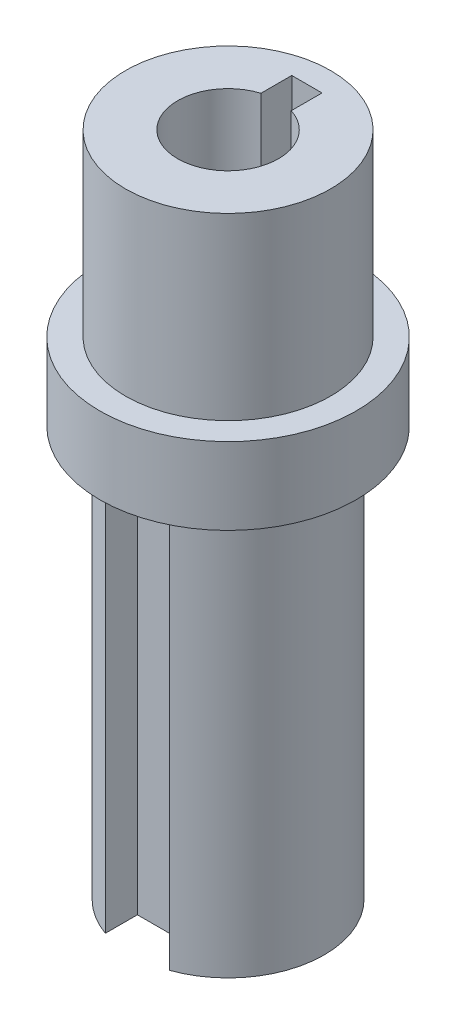
from build123d import *

# Parameters (mm, degrees)
CUT_EXTRUDE1_DEPTH = 21.8
CUT_EXTRUDE2_DEPTH = 39.37


with BuildPart() as part:
    # Sketch2 → Revolve1 (revolve)
    with BuildSketch(Plane.XY):
        Polygon((-10.16, 0), (-4.9911, 0), (-4.9911, -34.29), (-2.032, -34.29), (-2.032, -66.04), (-9.525, -66.04), (-9.525, -25.4), (-12.7, -25.4), (-12.7, -17.78), (-10.16, -17.78), align=None)
    revolve(axis=Axis((0, 0, 0), (0, -1, 0)))

    # Sketch4 → Cut-Extrude1 (cut)
    with BuildSketch(Plane(origin=(0, 0, 0), x_dir=(1, 0, 0), z_dir=(0, 1, 0))):
        with BuildLine():
            Line((1.5, 4.760365449), (1.5, 7.81))
            Line((1.5, 7.81), (-1.5, 7.81))
            Line((-1.5, 7.81), (-1.5, 4.760365449))
            ThreePointArc((-1.5, 4.760365449), (0, 4.9911), (1.5, 4.760365449))
        make_face()
    extrude(amount=-CUT_EXTRUDE1_DEPTH, mode=Mode.SUBTRACT)

    # Sketch5 → Cut-Extrude2 (cut)
    with BuildSketch(Plane.XZ.offset(66.04)):
        with BuildLine():
            Line((-3.175, 8.980256121), (-3.175, 5.805256121))
            Line((-3.175, 5.805256121), (3.175, 5.805256121))
            Line((3.175, 5.805256121), (3.175, 8.980256121))
            ThreePointArc((3.175, 8.980256121), (0, 9.525), (-3.175, 8.980256121))
        make_face()
    extrude(amount=-CUT_EXTRUDE2_DEPTH, mode=Mode.SUBTRACT)


solid = part.part
